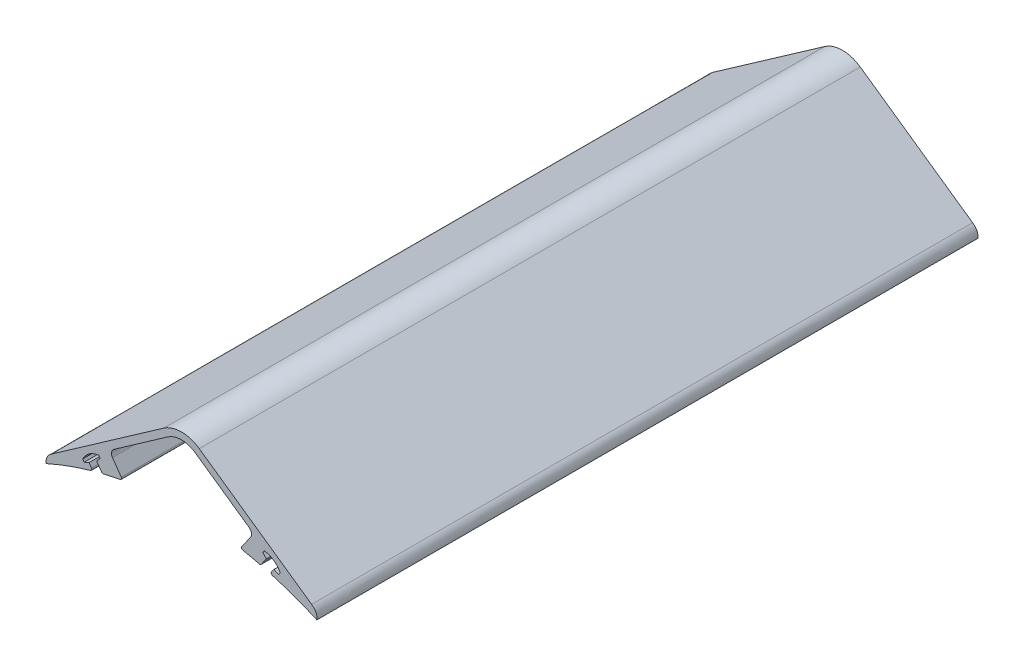
from build123d import *

# Parameters (mm, degrees)
BOSS_EXTRUDE1_DEPTH = 304.8
FILLET2_R           = 2.54
FILLET7_R           = 0.762


with BuildPart() as part:
    # Sketch1 → Boss-Extrude1 (new body)
    with BuildSketch(Plane.XY):
        with BuildLine():
            Line((-59.991213716, 144.035687339), (-8.193810242, 180.296949153))
            ThreePointArc((-8.193810242, 180.296949153), (0, 182.88), (8.193810242, 180.296949153))
            Line((8.193810242, 180.296949153), (59.991213716, 144.035687339))
            add(Edge.make_bspline(
                [(59.991213716, 144.035687339), (62.78248672, 142.0840471), (62.441206007, 139.021062406)],
                knots=[0, 0, 0, 1, 1, 1], degree=2))
            ThreePointArc((62.441206007, 139.021062406), (51.81191727, 143.32231239), (40.889317917, 146.812205488))
            Line((40.889317917, 146.812205488), (42.636417316, 149.30784982))
            Line((42.636417316, 149.30784982), (44.875008407, 148.34072044))
            Line((44.875008407, 148.34072044), (45.552343011, 149.308259131))
            add(Edge.make_bspline(
                [(45.552343011, 149.308259131), (43.180649259, 153.803743217), (38.144971739, 154.493859392)],
                knots=[0, 0, 0, 1, 1, 1], degree=2))
            Line((38.144971739, 154.493859392), (37.467637136, 153.526320702))
            Line((37.467637136, 153.526320702), (39.142437036, 151.753843735))
            Line((39.142437036, 151.753843735), (36.49122578, 147.966720721))
            ThreePointArc((36.49122578, 147.966720721), (31.806362047, 149.044004688), (27.089852549, 149.972997199))
            Line((27.089852549, 149.972997199), (33.300728714, 158.844923948))
            Line((33.300728714, 158.844923948), (6.372963522, 177.695960452))
            ThreePointArc((6.372963522, 177.695960452), (0, 179.705), (-6.372963522, 177.695960452))
            Line((-6.372963522, 177.695960452), (-33.300728714, 158.844923948))
            Line((-33.300728714, 158.844923948), (-27.089852549, 149.972997199))
            ThreePointArc((-27.089852549, 149.972997199), (-31.806362047, 149.044004688), (-36.49122578, 147.966720721))
            Line((-36.49122578, 147.966720721), (-39.142437036, 151.753843735))
            Line((-39.142437036, 151.753843735), (-37.467637136, 153.526320702))
            Line((-37.467637136, 153.526320702), (-38.144971739, 154.493859392))
            add(Edge.make_bspline(
                [(-45.552343011, 149.308259131), (-43.180649259, 153.803743217), (-38.144971739, 154.493859392)],
                knots=[0, 0, 0, 1, 1, 1], degree=2))
            Line((-45.552343011, 149.308259131), (-44.875008407, 148.34072044))
            Line((-44.875008407, 148.34072044), (-42.636417316, 149.30784982))
            Line((-42.636417316, 149.30784982), (-40.889317917, 146.812205488))
            ThreePointArc((-40.889317917, 146.812205488), (-51.81191727, 143.32231239), (-62.441206007, 139.021062406))
            add(Edge.make_bspline(
                [(-59.991213716, 144.035687339), (-62.78248672, 142.0840471), (-62.441206007, 139.021062406)],
                knots=[0, 0, 0, 1, 1, 1], degree=2))
        make_face()
    extrude(amount=BOSS_EXTRUDE1_DEPTH)

    # Fillet2
    fillet2_edges = [part.edges().sort_by_distance(p)[0] for p in [
        (33.300728714, 158.844923948, 152.4),
        (-33.300728714, 158.844923948, 152.4),
    ]]
    fillet(fillet2_edges, radius=FILLET2_R)

    # Fillet7
    fillet7_edges = [part.edges().sort_by_distance(p)[0] for p in [
        (40.889317917, 146.812205488, 152.4),
        (36.49122578, 147.966720721, 152.4),
        (27.089852549, 149.972997199, 152.4),
        (-27.089852549, 149.972997199, 152.4),
        (-36.49122578, 147.966720721, 152.4),
        (-40.889317917, 146.812205488, 152.4),
    ]]
    fillet(fillet7_edges, radius=FILLET7_R)


solid = part.part
